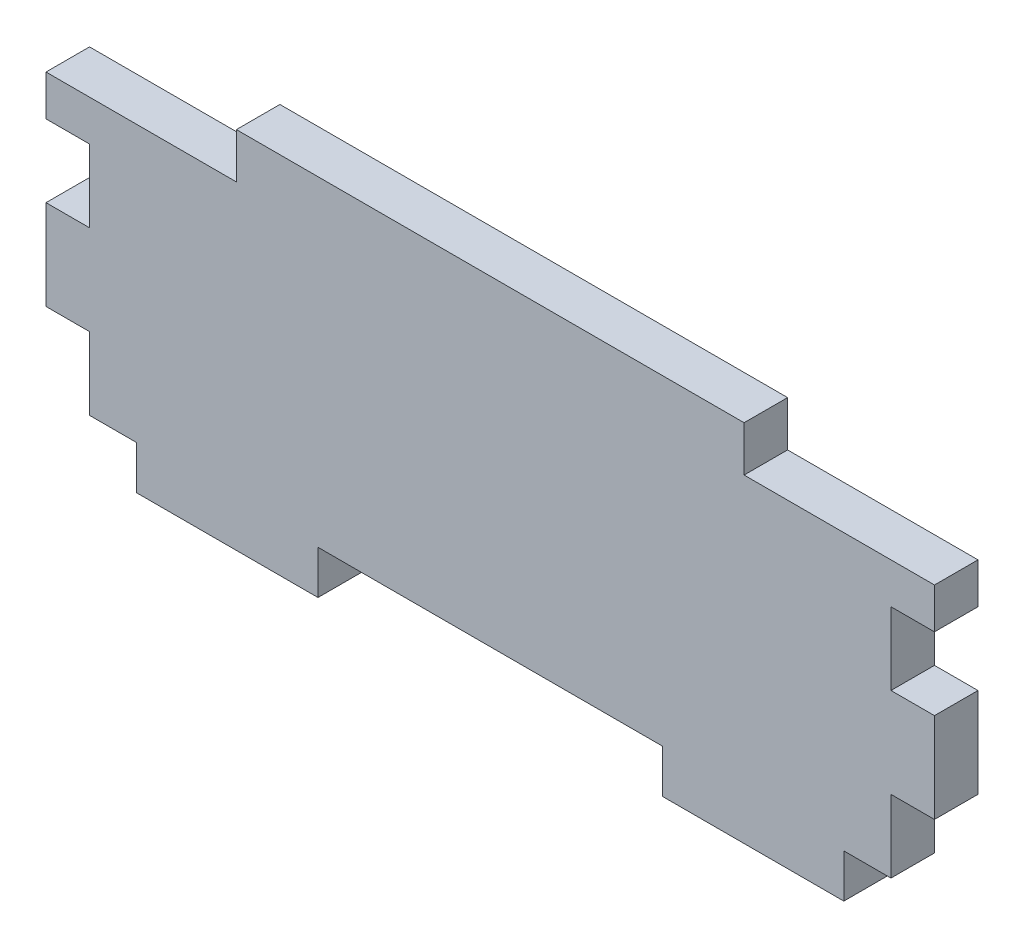
from build123d import *

# Parameters (mm, degrees)
BOSS_EXTRUDE1_DEPTH = 3.048


with BuildPart() as part:
    # Sketch1 → Boss-Extrude1 (new body)
    with BuildSketch(Plane.XY):
        Polygon((3.048, 9.8044), (0, 9.8044), (0, 4.7244), (-3.302, 4.7244), (-3.302, 1.6764), (-16.002, 1.6764), (-16.002, 4.7244), (-40.132, 4.7244), (-40.132, 1.6764), (-52.832, 1.6764), (-52.832, 4.7244), (-56.134, 4.7244), (-56.134, 9.8044), (-59.182, 9.8044), (-59.182, 16.1036), (-56.134, 16.1036), (-56.134, 21.1836), (-59.182, 21.1836), (-59.182, 24.0284), (-45.847, 24.0284), (-45.847, 27.2034), (-10.287, 27.2034), (-10.287, 24.0284), (3.048, 24.0284), (3.048, 21.1836), (0, 21.1836), (0, 16.1036), (3.048, 16.1036), align=None)
    extrude(amount=BOSS_EXTRUDE1_DEPTH)


solid = part.part
